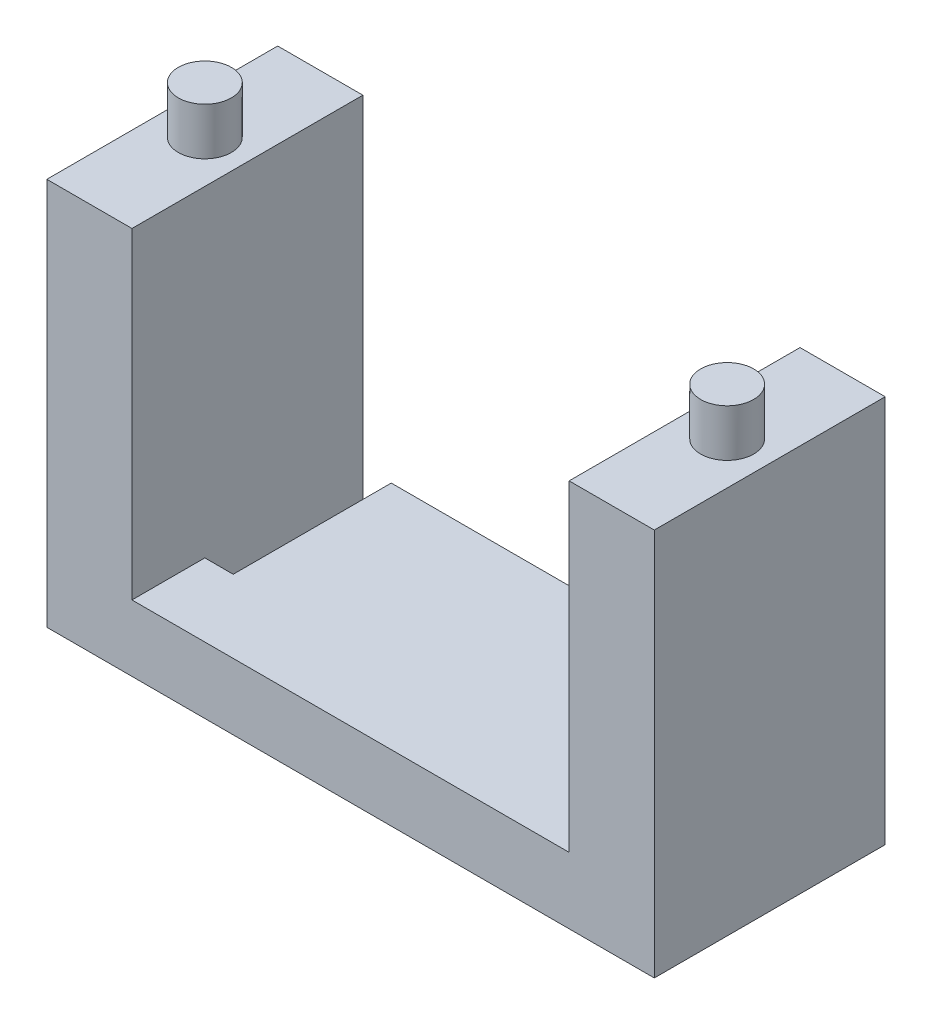
from build123d import *

# Parameters (mm, degrees)
EXTRUDE_2_DEPTH          = 12.2
SKETCH_5_W               = 1.5
SKETCH_5_H               = 8.35
CUT_EXTRUDE_1_DEPTH      = 22.5
SKETCH_6_R               = 1.4
EXTRUDE_3_DEPTH          = 2.5
SKETCH_7_W               = 12.2
SKETCH_7_H               = 1
CUT_EXTRUDE_2_DEPTH      = 1
CUT_EXTRUDE_2_DEPTH_BACK = 32.1


with BuildPart() as part:
    # 草图4 → 凸台-拉伸2 (new body)
    with BuildSketch(Plane.XY):
        Polygon((-11.55, 0), (11.55, 0), (11.55, 17), (16.05, 17), (16.05, -4.5), (-16.05, -4.5), (-16.05, 17), (-11.55, 17), align=None)
    extrude(amount=EXTRUDE_2_DEPTH)

    # 草图5 → 切除-拉伸1 (cut, through all)
    with BuildSketch(Plane.XZ.offset(4.5)):
        with Locations((-10.8, 4.175)):
            Rectangle(SKETCH_5_W, SKETCH_5_H)
    extrude(amount=-CUT_EXTRUDE_1_DEPTH, mode=Mode.SUBTRACT)

    # 草图6 → 凸台-拉伸3 (add)
    with BuildSketch(Plane(origin=(0, 17, 0), x_dir=(1, 0, 0), z_dir=(0, 1, 0))):
        with Locations((13.8, -6.1)):
            Circle(SKETCH_6_R)
        with Locations((-13.8, -6.1)):
            Circle(SKETCH_6_R)
    extrude(amount=EXTRUDE_3_DEPTH)

    # 草图7 → 切除-拉伸2 (cut, two sides)
    with BuildSketch(Plane(origin=(16.05, 0, 0), x_dir=(0, 0, -1), z_dir=(1, 0, 0))) as cut_extrude_2_sk:
        with Locations((-6.1, -4)):
            Rectangle(SKETCH_7_W, SKETCH_7_H)
    extrude(amount=CUT_EXTRUDE_2_DEPTH, mode=Mode.SUBTRACT)
    extrude(cut_extrude_2_sk.sketch, amount=-CUT_EXTRUDE_2_DEPTH_BACK, mode=Mode.SUBTRACT)


solid = part.part
